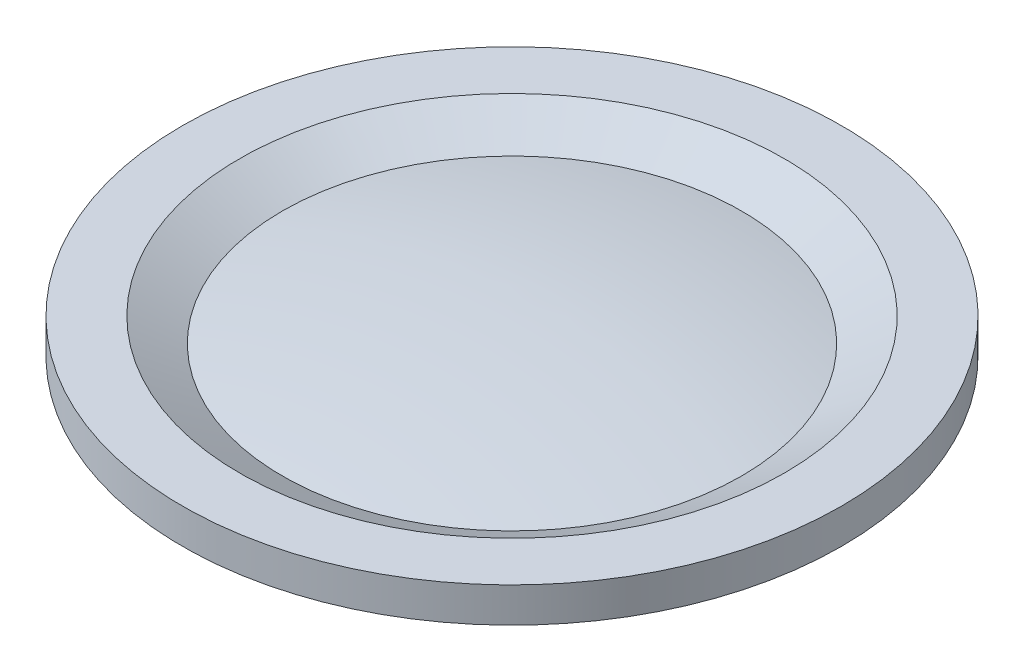
from build123d import *

# Parameters (mm, degrees)
BOSS_EXTRUDE1_DEPTH = 1.44


with BuildPart() as part:
    # Sketch1 → Revolve1 (revolve)
    with BuildSketch(Plane.XY, mode=Mode.PRIVATE) as revolve1_sk:
        with BuildLine():
            Line((0, 0), (-8.1, 0))
            Line((-8.1, 0), (-8.1, 1.6))
            Line((-8.1, 1.6), (-14.4, 1.6))
            Line((-14.4, 1.6), (-15.75, 2.95))
            Line((-15.75, 2.95), (-17.95, 2.95))
            Line((-17.95, 2.95), (-17.95, 4.85))
            Line((-17.95, 4.85), (-14.835133301, 4.85))
            Line((-14.835133301, 4.85), (-12.505491074, 3.546870113))
            ThreePointArc((-12.505491074, 3.546870113), (-6.286601914, 4.523337912), (0, 4.85))
            Line((0, 4.85), (0, 0))
        make_face()
    revolve(revolve1_sk.sketch.rotate(Axis((0, 0, 0), (0, 1, 0)), 180), axis=Axis((0, 0, 0), (0, 1, 0)))  # turned: the seam where the file's is


with BuildPart() as body_2:
    # Sketch2 → Boss-Extrude1 (new body)
    with BuildSketch(Plane.XZ.offset(-1.6)):
        with BuildLine():
            Line((-7.275, -4.771202679), (-7.275, -12.42716279))
            ThreePointArc((-7.275, -12.42716279), (0, -14.4), (7.275, -12.42716279))
            Line((7.275, -12.42716279), (7.275, -4.771202679))
            ThreePointArc((7.275, -4.771202679), (0, -8.7), (-7.275, -4.771202679))
        make_face()
    extrude(amount=BOSS_EXTRUDE1_DEPTH)


solid = Compound([part.part, body_2.part])
